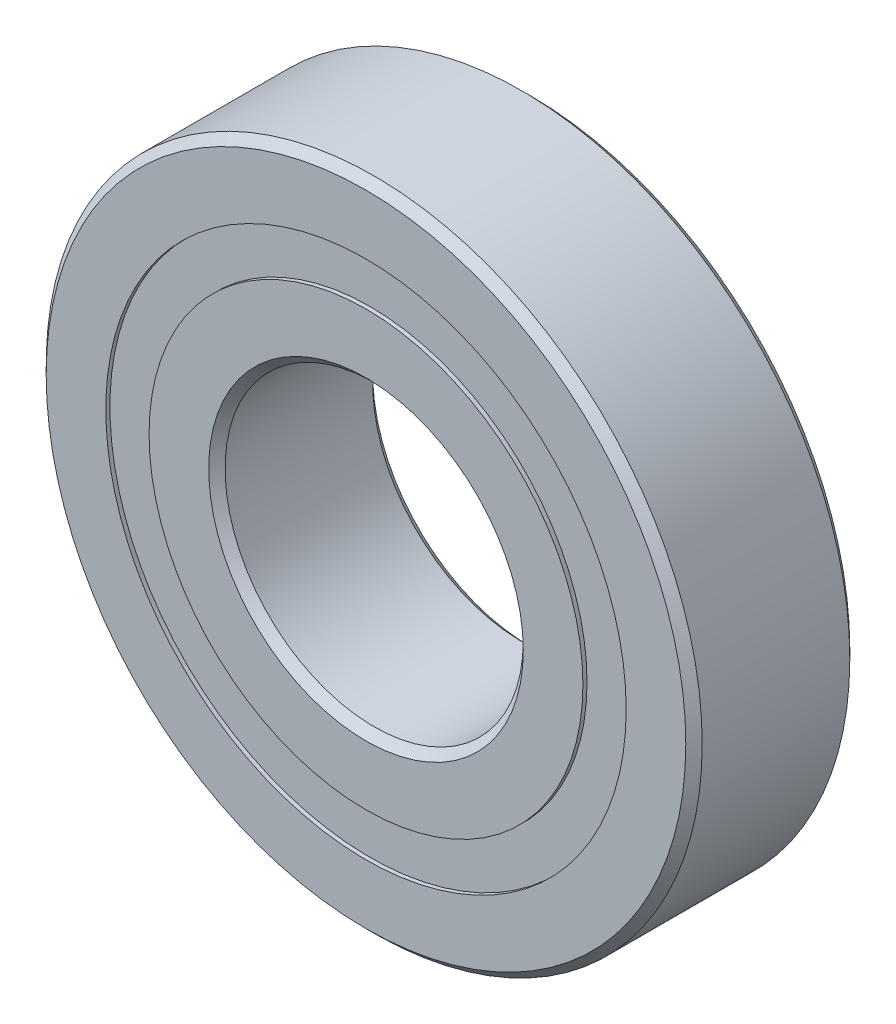
from build123d import *

# Parameters (mm, degrees)
CIRPATTERN1_COUNT = 10
SKETCH5_W         = 1.891165769
SKETCH5_H         = 2.302747252


with BuildPart() as part:
    # Sketch1 → Revolve1 (revolve)
    with BuildSketch(Plane(origin=(0, 0, 0), x_dir=(0, 0, -1), z_dir=(1, 0, 0))):
        with BuildLine():
            Line((3.9290625, 17.4625), (-3.9290625, 17.4625))
            Line((-3.9290625, 17.4625), (-4.365625, 17.0259375))
            Line((-4.365625, 17.0259375), (-4.365625, 13.851373626))
            Line((-4.365625, 13.851373626), (-1.940277778, 13.851373626))
            ThreePointArc((-1.940277778, 13.851373626), (0, 14.956177981), (1.940277778, 13.851373626))
            Line((1.940277778, 13.851373626), (4.365625, 13.851373626))
            Line((4.365625, 13.851373626), (4.365625, 17.0259375))
            Line((4.365625, 17.0259375), (3.9290625, 17.4625))
        make_face()
    revolve(axis=Axis((0, 0, 4.365625), (0, 0, -1)))


with BuildPart() as body_2:
    # Sketch3 → Revolve3 (revolve)
    with BuildSketch(Plane(origin=(0, 0, 0), x_dir=(0, 0, -1), z_dir=(1, 0, 0))):
        with BuildLine():
            Line((-4.365625, 11.548626374), (-1.940277778, 11.548626374))
            ThreePointArc((-1.940277778, 11.548626374), (0, 10.443822019), (1.940277778, 11.548626374))
            Line((1.940277778, 11.548626374), (4.365625, 11.548626374))
            Line((4.365625, 11.548626374), (4.365625, 8.3740625))
            Line((4.365625, 8.3740625), (3.9290625, 7.9375))
            Line((3.9290625, 7.9375), (-3.9290625, 7.9375))
            Line((-3.9290625, 7.9375), (-4.365625, 8.3740625))
            Line((-4.365625, 8.3740625), (-4.365625, 11.548626374))
        make_face()
    revolve(axis=Axis((0, 0, 4.365625), (0, 0, -1)))


with BuildPart() as body_3:
    # Sketch4 → Revolve4 (revolve)
    with BuildSketch(Plane(origin=(0, 0, 0), x_dir=(0, 0, -1), z_dir=(1, 0, 0))):
        with BuildLine():
            Line((-2.256177981, 12.7), (2.256177981, 12.7))
            ThreePointArc((2.256177981, 12.7), (0, 14.956177981), (-2.256177981, 12.7))
        make_face()
    revolve(axis=Axis((0, 12.7, 2.256177981), (0, 0, -1)))


with BuildPart() as cirpattern1_1:
    # CirPattern1: pattern copy
    add(body_3.part.rotate(Axis((0, 0, 0), (0, 0, 1)), 1 * 360 / CIRPATTERN1_COUNT))


with BuildPart() as cirpattern1_2:
    # CirPattern1: pattern copy
    add(body_3.part.rotate(Axis((0, 0, 0), (0, 0, 1)), 2 * 360 / CIRPATTERN1_COUNT))


with BuildPart() as cirpattern1_3:
    # CirPattern1: pattern copy
    add(body_3.part.rotate(Axis((0, 0, 0), (0, 0, 1)), 3 * 360 / CIRPATTERN1_COUNT))


with BuildPart() as cirpattern1_4:
    # CirPattern1: pattern copy
    add(body_3.part.rotate(Axis((0, 0, 0), (0, 0, 1)), 4 * 360 / CIRPATTERN1_COUNT))


with BuildPart() as cirpattern1_5:
    # CirPattern1: pattern copy
    add(body_3.part.rotate(Axis((0, 0, 0), (0, 0, 1)), 5 * 360 / CIRPATTERN1_COUNT))


with BuildPart() as cirpattern1_6:
    # CirPattern1: pattern copy
    add(body_3.part.rotate(Axis((0, 0, 0), (0, 0, 1)), 6 * 360 / CIRPATTERN1_COUNT))


with BuildPart() as cirpattern1_7:
    # CirPattern1: pattern copy
    add(body_3.part.rotate(Axis((0, 0, 0), (0, 0, 1)), 7 * 360 / CIRPATTERN1_COUNT))


with BuildPart() as cirpattern1_8:
    # CirPattern1: pattern copy
    add(body_3.part.rotate(Axis((0, 0, 0), (0, 0, 1)), 8 * 360 / CIRPATTERN1_COUNT))


with BuildPart() as cirpattern1_9:
    # CirPattern1: pattern copy
    add(body_3.part.rotate(Axis((0, 0, 0), (0, 0, 1)), 9 * 360 / CIRPATTERN1_COUNT))


with BuildPart() as body_13:
    # Sketch5 → Revolve5 (revolve)
    with BuildSketch(Plane(origin=(0, 0, 0), x_dir=(0, 0, -1), z_dir=(1, 0, 0))):
        with Locations((-3.201760865, 12.7)):
            Rectangle(SKETCH5_W, SKETCH5_H)
        with Locations((3.201760865, 12.7)):
            Rectangle(SKETCH5_W, SKETCH5_H)
    revolve(axis=Axis((0, 0, 4.365625), (0, 0, -1)))


solid = Compound([part.part, body_2.part, body_3.part, cirpattern1_1.part, cirpattern1_2.part, cirpattern1_3.part, cirpattern1_4.part, cirpattern1_5.part, cirpattern1_6.part, cirpattern1_7.part, cirpattern1_8.part, cirpattern1_9.part, body_13.part])
